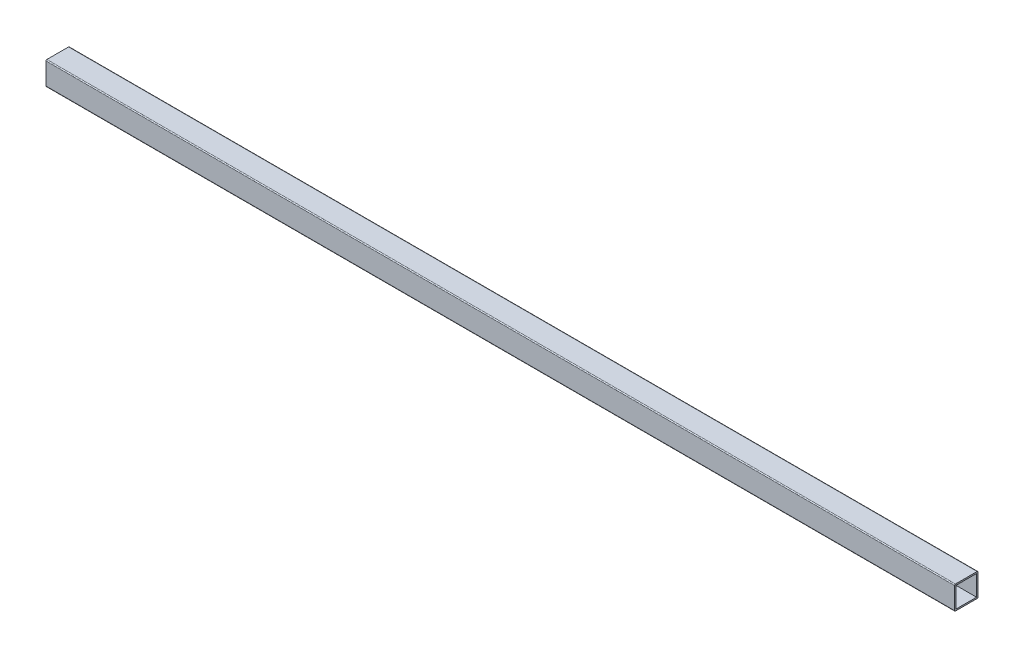
from build123d import *

# Parameters (mm, degrees)
SKETCH2_W                = 25.54
SKETCH2_H                = 25.54
SKETCH2_W_2              = 22.365
SKETCH2_H_2              = 22.365
BOSS_EXTRUDE1_DEPTH      = 400
BOSS_EXTRUDE1_DEPTH_BACK = 590
FILLET1_R                = 1


with BuildPart() as part:
    # Sketch2 → Boss-Extrude1 (new body, two sides)
    with BuildSketch(Plane(origin=(0, 0, 0), x_dir=(0, 0, -1), z_dir=(1, 0, 0))) as boss_extrude1_sk:
        Rectangle(SKETCH2_W, SKETCH2_H)
        Rectangle(SKETCH2_W_2, SKETCH2_H_2, mode=Mode.SUBTRACT)
    extrude(amount=BOSS_EXTRUDE1_DEPTH)
    extrude(boss_extrude1_sk.sketch, amount=-BOSS_EXTRUDE1_DEPTH_BACK)

    # Fillet1
    fillet1_edges = [part.edges().sort_by_distance(p)[0] for p in [
        (-95, -12.77, -12.77),
        (-95, -12.77, 12.77),
        (-95, 12.77, 12.77),
        (-95, 12.77, -12.77),
    ]]
    fillet(fillet1_edges, radius=FILLET1_R)


solid = part.part
